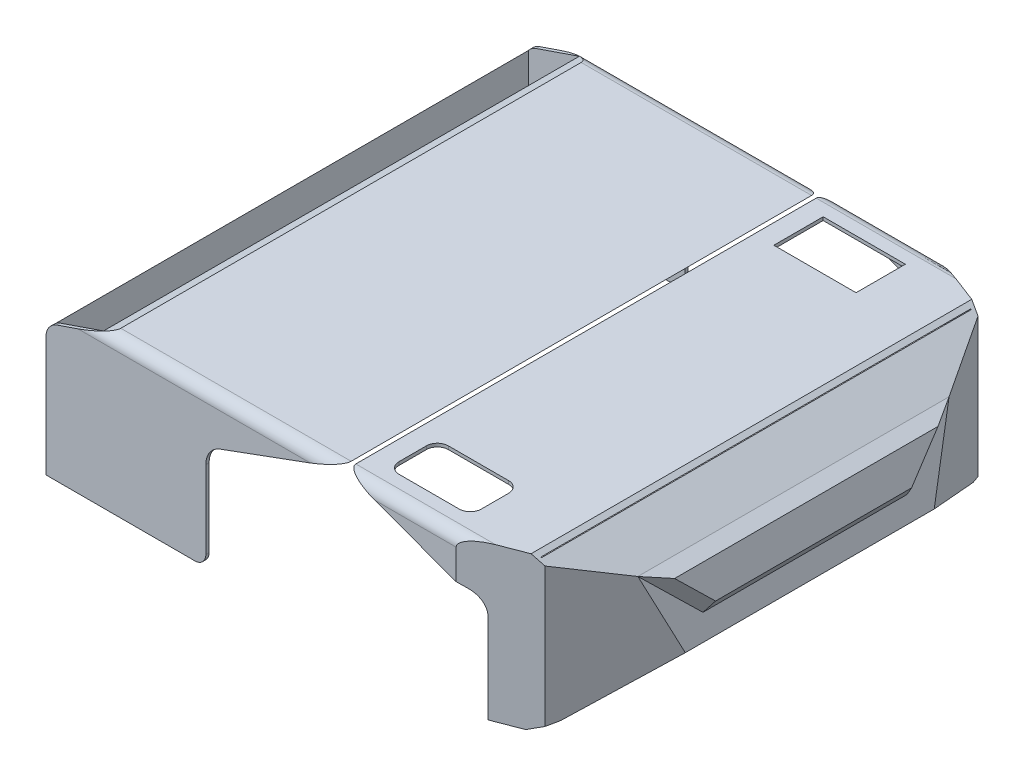
from build123d import *

# Parameters (mm, degrees)
SKETCH1_W           = 480
SKETCH1_H           = 140
BOSS_EXTRUDE1_DEPTH = 440
CUT_EXTRUDE2_DEPTH  = 441
CHAMFER1_SIZE       = 15
CHAMFER1_SIZE2      = 47.347217079
CUT_EXTRUDE3_DEPTH  = 335
FILLET1_R           = 10
FILLET2_R           = 15
BOSS_EXTRUDE2_DEPTH = 10
BOSS_EXTRUDE2_TAPER = 42
CUT_EXTRUDE4_DEPTH  = 137
SKETCH8_W           = 75
SKETCH8_H           = 45
CUT_EXTRUDE5_DEPTH  = 10
CUT_EXTRUDE6_DEPTH  = 674
CUT_EXTRUDE7_DEPTH  = 441
FILLET3_R           = 10


with BuildPart() as part:
    # Sketch1 → Boss-Extrude1 (new body)
    with BuildSketch(Plane.XY):
        with Locations((240, 70)):
            Rectangle(SKETCH1_W, SKETCH1_H)
    extrude(amount=BOSS_EXTRUDE1_DEPTH)

    # Sketch3 → Cut-Extrude2 (cut, through all)
    with BuildSketch(Plane.XY.offset(440)):
        Polygon((0, 120), (58.225421292, 140), (423.483139802, 140), (461.850368806, 111.690568425), (480, 30.060272778), (420, 0), (591.519627261, 0), (591.519627261, 186.002843458), (0, 186.002843458), align=None)
    extrude(amount=-CUT_EXTRUDE2_DEPTH, mode=Mode.SUBTRACT)

    # Chamfer1
    chamfer1_edges = [part.edges().sort_by_distance(p)[0] for p in [
        (480, 30.060272778, 220),
    ]]
    chamfer1_side = [part.faces().sort_by_distance(p)[0] for p in [
        (470.925184403, 70.875420602, 220),
    ]]
    chamfer(chamfer1_edges, length=CHAMFER1_SIZE, length2=CHAMFER1_SIZE2, reference=chamfer1_side[0])

    # Sketch4 → Cut-Extrude3 (cut)
    with BuildSketch(Plane(origin=(0, 140, 0), x_dir=(1, 0, 0), z_dir=(0, 1, 0))):
        Polygon((476.744408085, -333.53246978), (476.744408085, -106.46753022), (432.760156683, -22.553519937), (374.146970562, 0), (571.445259905, 0), (571.445259905, -440), (374.146970562, -440), (432.760156683, -417.446480063), align=None)
    extrude(amount=-CUT_EXTRUDE3_DEPTH, mode=Mode.SUBTRACT)

    # Fillet1
    fillet1_edges = [part.edges().sort_by_distance(p)[0] for p in [
        (216.186195927, 140, 0),
        (216.186195927, 140, 440),
    ]]
    fillet(fillet1_edges, radius=FILLET1_R)

    # Fillet2
    fillet2_edges = [part.edges().sort_by_distance(p)[0] for p in [
        (0, 120, 220),
    ]]
    fillet(fillet2_edges, radius=FILLET2_R)

    # Sketch6 → Boss-Extrude2 (add)
    with BuildSketch(Plane(origin=(463.757804126, 103.111633269, 0), x_dir=(0, 0, -1), z_dir=(0.976162831, 0.217039461, 0))):
        Polygon((-361.947607595, 8.788426361), (-313.097540887, -39.835220293), (-126.902459113, -39.835220293), (-78.052392405, 8.788426361), align=None)
    extrude(amount=BOSS_EXTRUDE2_DEPTH, taper=BOSS_EXTRUDE2_TAPER)

    # Sketch7 → Cut-Extrude4 (cut)
    with BuildSketch(Plane.XZ):
        Polygon((428.050265386, 416.044352233), (373.589707288, 437), (3, 437), (3, 3), (373.589707288, 3), (428.050265386, 23.955647767), align=None)
    extrude(amount=-CUT_EXTRUDE4_DEPTH, mode=Mode.SUBTRACT)

    # Sketch8 → Cut-Extrude5 (cut)
    with BuildSketch(Plane(origin=(0, 140, 0), x_dir=(1, 0, 0), z_dir=(0, 1, 0))):
        with BuildLine():
            Line((300.5, -373.462859875), (355.5, -373.462859875))
            ThreePointArc((355.5, -373.462859875), (362.571067812, -376.391792064), (365.5, -383.462859875))
            Line((365.5, -383.462859875), (365.5, -408.462859875))
            ThreePointArc((365.5, -408.462859875), (362.571067812, -415.533927687), (355.5, -418.462859875))
            Line((355.5, -418.462859875), (300.5, -418.462859875))
            ThreePointArc((300.5, -418.462859875), (293.428932188, -415.533927687), (290.5, -408.462859875))
            Line((290.5, -408.462859875), (290.5, -383.462859875))
            ThreePointArc((290.5, -383.462859875), (293.428932188, -376.391792064), (300.5, -373.462859875))
        make_face()
        with Locations((328, -44.037140125)):
            Rectangle(SKETCH8_W, SKETCH8_H)
    extrude(amount=-CUT_EXTRUDE5_DEPTH, mode=Mode.SUBTRACT)

    # Sketch9 → Cut-Extrude6 (cut)
    with BuildSketch(Plane.XY.offset(440)):
        with BuildLine():
            Line((270.5, 140.775139833), (158.917057954, 99.850098536))
            ThreePointArc((158.917057954, 99.850098536), (149.406641197, 92.524488549), (145.803826482, 81.07318667))
            Line((145.803826482, 81.07318667), (145.803826482, 0))
            Line((145.803826482, 0), (395.196173518, 0))
            Line((395.196173518, 0), (395.196173518, 81.07318667))
            ThreePointArc((395.196173518, 81.07318667), (391.593358803, 92.524488549), (382.082942046, 99.850098536))
            Line((382.082942046, 99.850098536), (270.5, 140.775139833))
        make_face()
    extrude(amount=-CUT_EXTRUDE6_DEPTH, mode=Mode.SUBTRACT)

    # Sketch10 → Cut-Extrude7 (cut, through all)
    with BuildSketch(Plane.XY.offset(440)):
        with BuildLine():
            Line((360.196173518, 33.996583279), (319.600106703, 53.851341534))
            ThreePointArc((319.600106703, 53.851341534), (323.689977769, 50.162754432), (325.206613776, 44.8681784))
            Line((325.206613776, 44.8681784), (325.206613776, 0))
            Line((325.206613776, 0), (360.196173518, 0))
            Line((360.196173518, 0), (360.196173518, 33.996583279))
        make_face()
    extrude(amount=-CUT_EXTRUDE7_DEPTH, mode=Mode.SUBTRACT)

    # Fillet3
    fillet3_edges = [part.edges().sort_by_distance(p)[0] for p in [
        (145.803826482, 0, 1.5),
        (145.803826482, 0, 438.5),
    ]]
    fillet(fillet3_edges, radius=FILLET3_R)


solid = part.part
